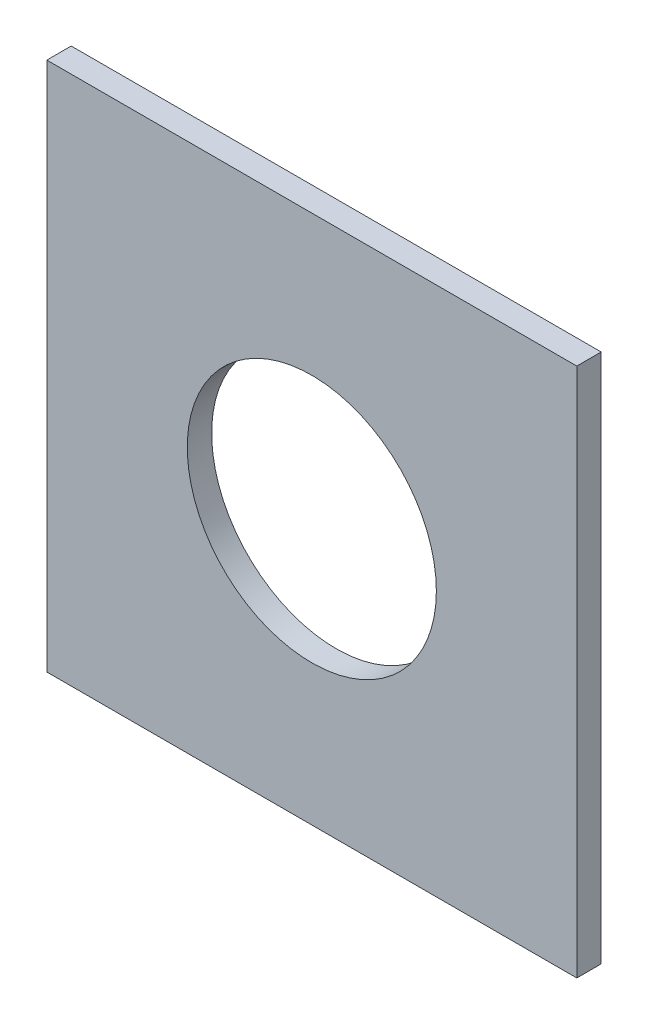
from build123d import *

# Parameters (mm, degrees)
ESQUISSE1_W        = 100
ESQUISSE1_H        = 100
ESQUISSE1_R        = 23.5
BOSS_EXTRU_1_DEPTH = 4.6


with BuildPart() as part:
    # Esquisse1 → Boss.-Extru.1 (new body)
    with BuildSketch(Plane.XY):
        with Locations((5.828319543, -13.849884125)):
            Rectangle(ESQUISSE1_W, ESQUISSE1_H)
        with Locations((5.828319543, -13.849884125)):
            Circle(ESQUISSE1_R, mode=Mode.SUBTRACT)
    extrude(amount=BOSS_EXTRU_1_DEPTH)


solid = part.part
